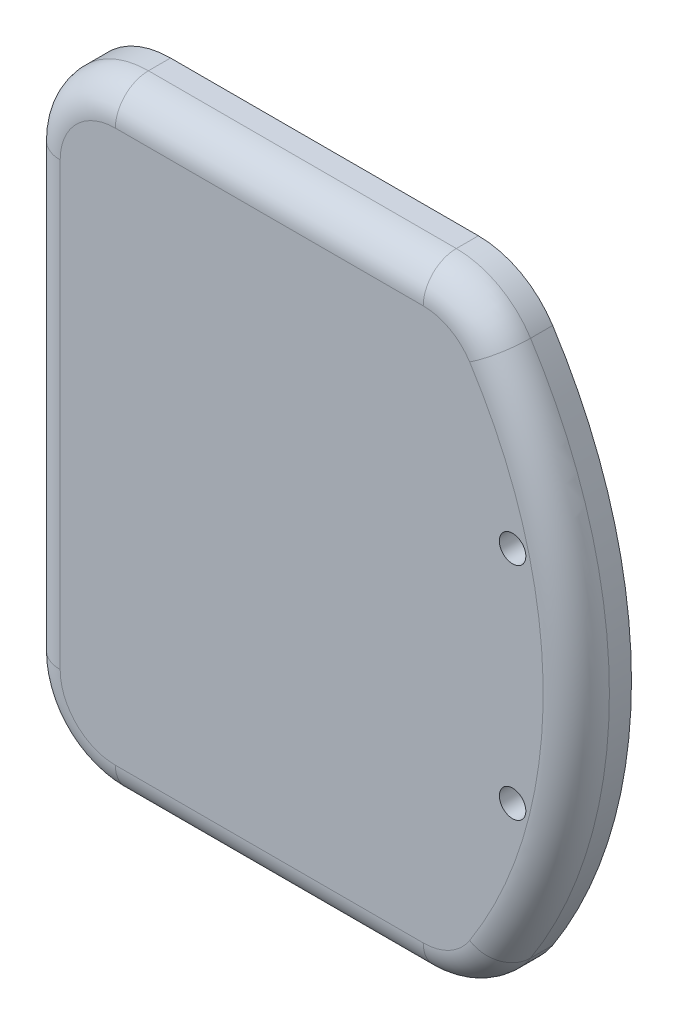
from build123d import *

# Parameters (mm, degrees)
EXTRUDE_1_DEPTH       = 5
FILLET_3_R            = 8
FILLET_4_R            = 3
HOLE_WIZARD_M32_D     = 2.4
HOLE_WIZARD_M32_DEPTH = 9.278967257
HOLE_WIZARD_M32_TIP   = 0.721032743


with BuildPart() as part:
    # Эскиз1 → Бобышка-Вытянуть1 (new body)
    with BuildSketch(Plane.XY):
        with BuildLine():
            Line((0, 0), (40, 0))
            ThreePointArc((40, 0), (49.772170092, 28), (40, 56))
            Line((40, 56), (0, 56))
            Line((0, 56), (0, 0))
        make_face()
    extrude(amount=-EXTRUDE_1_DEPTH)

    # Скругление3
    fillet_3_edges = [part.edges().sort_by_distance(p)[0] for p in [
        (0, 0, -2.5),
        (0, 56, -2.5),
        (40, 56, -2.5),
        (40, 0, -2.5),
    ]]
    fillet(fillet_3_edges, radius=FILLET_3_R)

    # Скругление4
    fillet_4_edges = [part.edges().sort_by_distance(p)[0] for p in [
        (49.772170092, 28, 0),
        (21.950467462, 0, 0),
        (21.950467462, 56, 0),
        (0, 28, 0),
        (2.343145751, 53.656854249, 0),
        (2.343145751, 2.343145751, 0),
        (39.735345271, 0.978796592, 0),
        (39.735345271, 55.021203408, 0),
    ]]
    fillet(fillet_4_edges, radius=FILLET_4_R)

    # Отверстие с зазором M32
    with Locations(Plane.XY):
        with Locations((44, 38), (44, 18)):
            Hole(HOLE_WIZARD_M32_D / 2, depth=HOLE_WIZARD_M32_DEPTH)
            with Locations((0, 0, -(HOLE_WIZARD_M32_DEPTH + HOLE_WIZARD_M32_TIP / 2))):  # 118° drill point
                Cone(0, HOLE_WIZARD_M32_D / 2, HOLE_WIZARD_M32_TIP, mode=Mode.SUBTRACT)


solid = part.part
